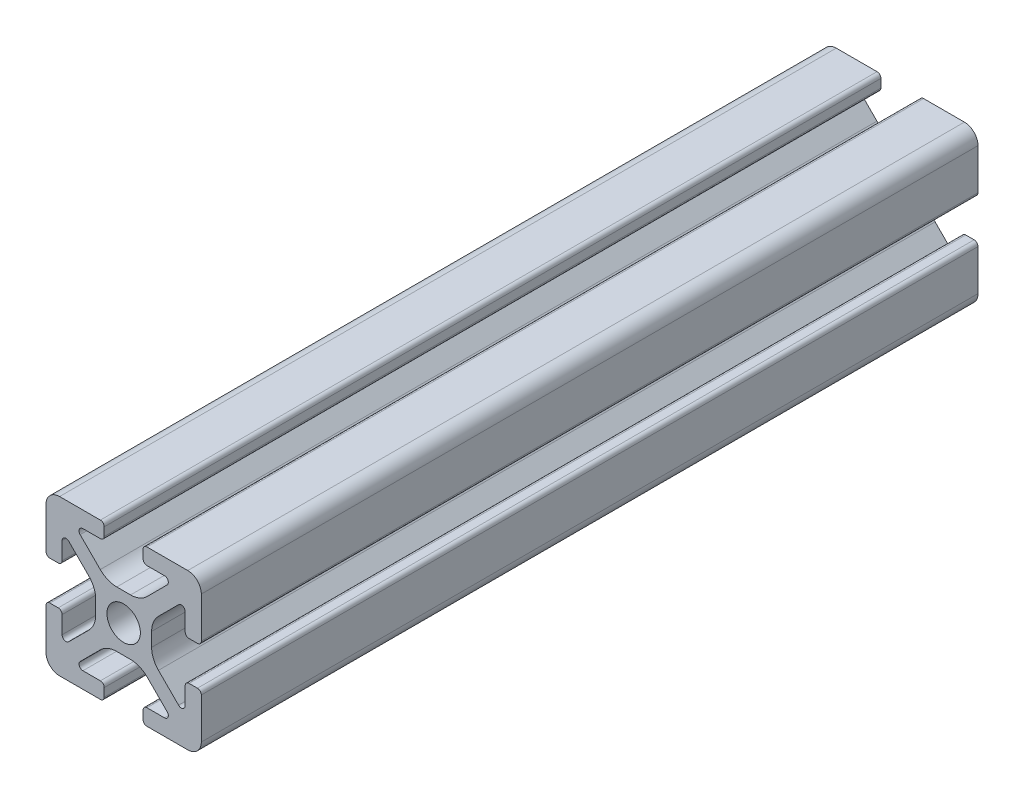
from build123d import *

# Parameters (mm, degrees)
BOSS_EXTRUDE1_DEPTH = 50


with BuildPart() as part:
    # Sketch4 → Boss-Extrude1 (new body, symmetric)
    with BuildSketch(Plane.XY):
        with BuildLine():
            Line((3, -10), (8.25, -10))
            ThreePointArc((8.25, -10), (9.487436867, -9.487436867), (10, -8.25))
            Line((10, -8.25), (10, -3))
            ThreePointArc((10, -3), (9.853553391, -2.646446609), (9.5, -2.5))
            Line((9.5, -2.5), (8.424621202, -2.5))
            ThreePointArc((8.424621202, -2.5), (8.071067812, -2.646446609), (7.924621202, -3))
            Line((7.924621202, -3), (7.924621202, -5.25))
            ThreePointArc((7.924621202, -5.25), (7.615962919, -5.711939766), (7.071067812, -5.603553391))
            Line((7.071067812, -5.603553391), (4.478679656, -3.011165235))
            ThreePointArc((4.478679656, -3.011165235), (3.828361402, -2.037895189), (3.6, -0.889844892))
            Line((3.6, -0.889844892), (3.6, 0))
            Line((3.6, 0), (2.15, 0))
            ThreePointArc((2.15, 0), (1.52027958, -1.52027958), (0, -2.15))
            Line((0, -2.15), (0, -3.6))
            Line((0, -3.6), (0.889844892, -3.6))
            ThreePointArc((0.889844892, -3.6), (2.037895189, -3.828361402), (3.011165235, -4.478679656))
            Line((3.011165235, -4.478679656), (5.603553391, -7.071067812))
            ThreePointArc((5.603553391, -7.071067812), (5.711939766, -7.615962919), (5.25, -7.924621202))
            Line((5.25, -7.924621202), (3, -7.924621202))
            ThreePointArc((3, -7.924621202), (2.646446609, -8.071067812), (2.5, -8.424621202))
            Line((2.5, -8.424621202), (2.5, -9.5))
            ThreePointArc((2.5, -9.5), (2.646446609, -9.853553391), (3, -10))
        make_face()
    extrude(amount=BOSS_EXTRUDE1_DEPTH, both=True)

    # Mirror1: part across plane


with BuildPart() as part_1:
    add(part.part)
    add(part.part.mirror(Plane(origin=(0, 0, 0), x_dir=(0, 0, 1), z_dir=(1, 0, 0))))

    # Mirror2: part across plane


with BuildPart() as part_2:
    add(part_1.part)
    add(part_1.part.mirror(Plane.ZX))


solid = part_2.part
